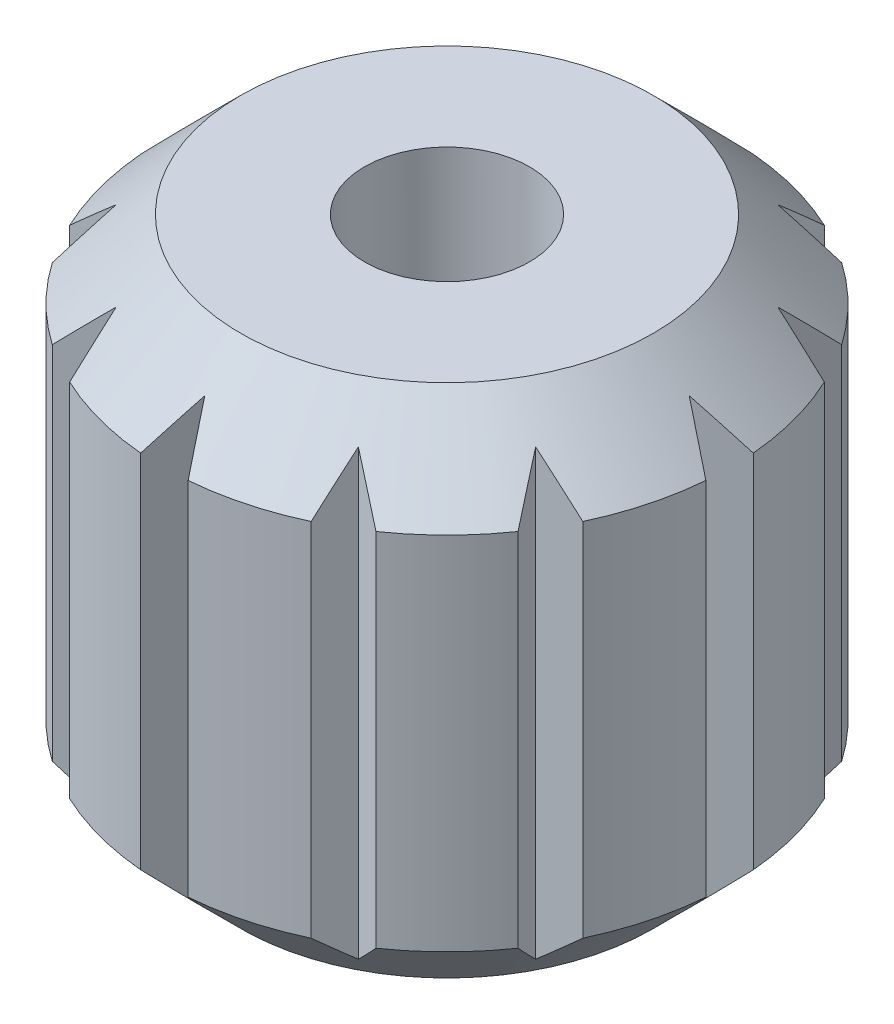
from build123d import *

# Parameters (mm, degrees)
CUT_EXTRUDE1_DEPTH = 11
CUT_EXTRUDE2_DEPTH = 2.8


with BuildPart() as part:
    # Sketch1 → Revolve1 (revolve)
    with BuildSketch(Plane.XY):
        Polygon((1.6, 0), (4, 0), (5.5, 1.5), (5.5, 8.5), (4, 10), (1.6, 10), align=None)
    revolve(axis=Axis((0, 9.5, 0), (0, -1, 0)))

    # Sketch2 → Cut-Extrude1 (cut, through all)
    with BuildSketch(Plane(origin=(0, 10, 0), x_dir=(1, 0, 0), z_dir=(0, 1, 0))):
        Polygon((-0.849983323, 6.145149701), (0, 4.697880799), (0.849983323, 6.145149701), align=None)
        Polygon((3.808682001, 4.896864089), (2.3364677, 5.746847412), (2.3489404, 4.068484116), align=None)
        Polygon((5.746847412, 2.3364677), (4.896864089, 3.808682001), (4.068484116, 2.3489404), align=None)
        Polygon((6.145149701, -0.849983323), (6.145149701, 0.849983323), (4.697880799, 0), align=None)
        Polygon((4.896864089, -3.808682001), (5.746847412, -2.3364677), (4.068484116, -2.3489404), align=None)
        Polygon((2.3364677, -5.746847412), (3.808682001, -4.896864089), (2.3489404, -4.068484116), align=None)
        Polygon((-0.849983323, -6.145149701), (0.849983323, -6.145149701), (0, -4.697880799), align=None)
        Polygon((-3.808682001, -4.896864089), (-2.3364677, -5.746847412), (-2.3489404, -4.068484116), align=None)
        Polygon((-5.746847412, -2.3364677), (-4.896864089, -3.808682001), (-4.068484116, -2.3489404), align=None)
        Polygon((-6.145149701, 0.849983323), (-6.145149701, -0.849983323), (-4.697880799, 0), align=None)
        Polygon((-4.896864089, 3.808682001), (-5.746847412, 2.3364677), (-4.068484116, 2.3489404), align=None)
        Polygon((-2.3364677, 5.746847412), (-3.808682001, 4.896864089), (-2.3489404, 4.068484116), align=None)
    extrude(amount=-CUT_EXTRUDE1_DEPTH, mode=Mode.SUBTRACT)

    # Sketch3 → Cut-Extrude2 (cut)
    with BuildSketch(Plane(origin=(0, 3, 0), x_dir=(-1, 0, 0), z_dir=(0, -1, 0))):
        Polygon((1.674315781, 2.9), (-1.674315781, 2.9), (-3.348631561, 0), (-1.674315781, -2.9), (1.674315781, -2.9), (3.348631561, 0), align=None)
    extrude(amount=-CUT_EXTRUDE2_DEPTH, mode=Mode.SUBTRACT)


solid = part.part
